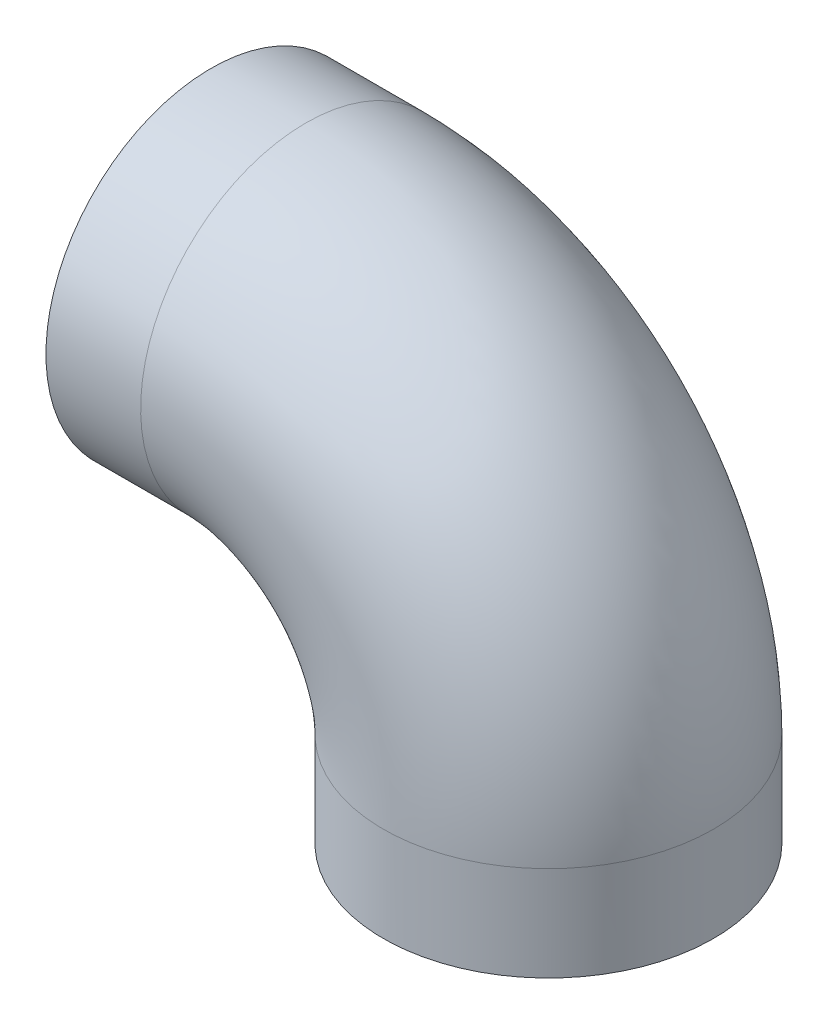
from build123d import *

# Parameters (mm, degrees)
SKETCH1_R          = 88.5571
SKETCH1_R_2        = 72.5043
SKETCH3_R          = 84.1375
CUT_EXTRUDE1_DEPTH = 44.45
SKETCH4_R          = 84.1375
CUT_EXTRUDE2_DEPTH = 44.45


with BuildPart() as part:
    # Sweep1: sweep along a path in Sketch2
    with BuildLine(Plane.XY) as sweep1_path:
        Line((0, 0), (50.8, 0))
        ThreePointArc((50.8, 0), (142.847625241, -38.127374759), (180.975, -130.175))
        Line((180.975, -130.175), (180.975, -180.975))
    # Sketch1 → Sweep1 (sweep)
    with BuildSketch(Plane(origin=(0, 0, 0), x_dir=(0, 0, -1), z_dir=(1, 0, 0))):
        Circle(SKETCH1_R)
        Circle(SKETCH1_R_2, mode=Mode.SUBTRACT)
    sweep(path=sweep1_path.line)

    # Sketch3 → Cut-Extrude1 (cut)
    with BuildSketch(Plane(origin=(0, -180.975, 0), x_dir=(-1, 0, 0), z_dir=(0, -1, 0))):
        with Locations((-180.975, 0)):
            Circle(SKETCH3_R)
    extrude(amount=-CUT_EXTRUDE1_DEPTH, mode=Mode.SUBTRACT)

    # Sketch4 → Cut-Extrude2 (cut)
    with BuildSketch(Plane.ZY):
        Circle(SKETCH4_R)
    extrude(amount=-CUT_EXTRUDE2_DEPTH, mode=Mode.SUBTRACT)


solid = part.part
